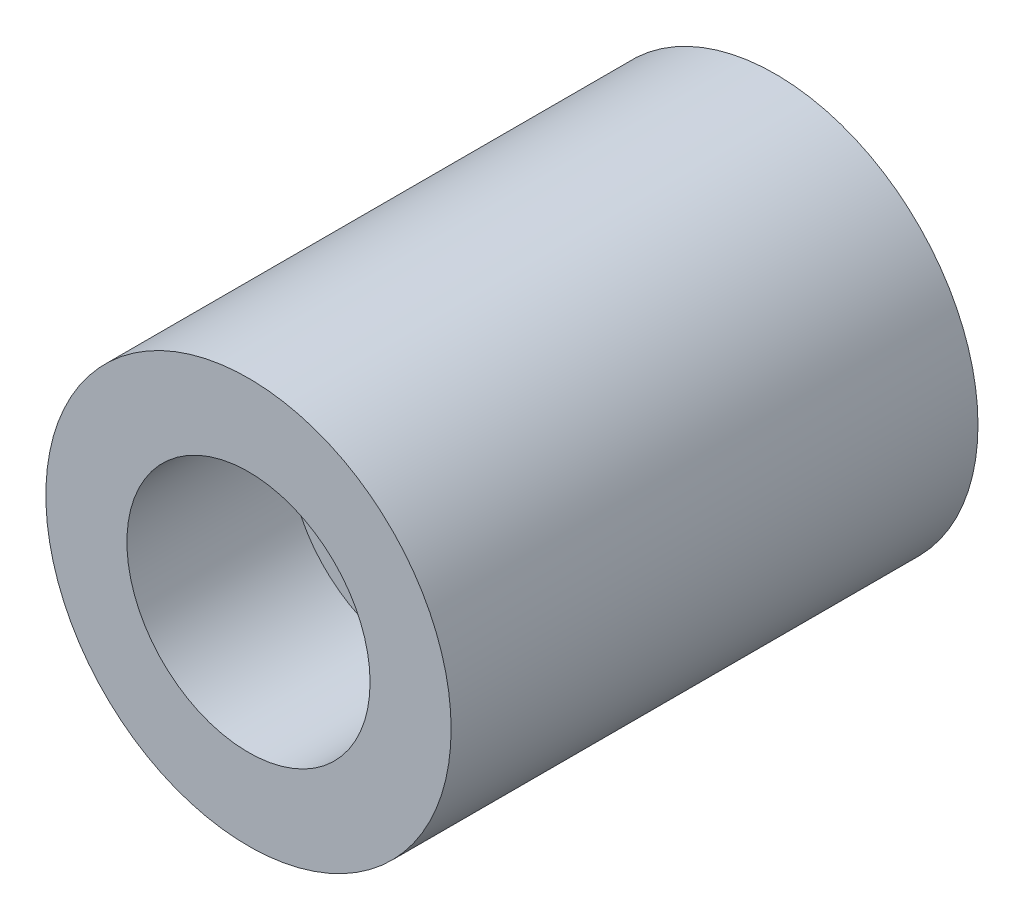
from build123d import *

# Parameters (mm, degrees)
SKETCH1_R           = 50
BOSS_EXTRUDE1_DEPTH = 130
SKETCH2_R           = 30
CUT_EXTRUDE1_DEPTH  = 40
SKETCH3_R           = 10
CUT_EXTRUDE2_DEPTH  = 80


with BuildPart() as part:
    # Sketch1 → Boss-Extrude1 (new body)
    with BuildSketch(Plane.XY):
        Circle(SKETCH1_R)
    extrude(amount=BOSS_EXTRUDE1_DEPTH)

    # Sketch2 → Cut-Extrude1 (cut)
    with BuildSketch(Plane.XY.offset(130)):
        Circle(SKETCH2_R)
    extrude(amount=-CUT_EXTRUDE1_DEPTH, mode=Mode.SUBTRACT)

    # Sketch3 → Cut-Extrude2 (cut)
    with BuildSketch(Plane.XY.offset(90)):
        Circle(SKETCH3_R)
    extrude(amount=-CUT_EXTRUDE2_DEPTH, mode=Mode.SUBTRACT)


solid = part.part
